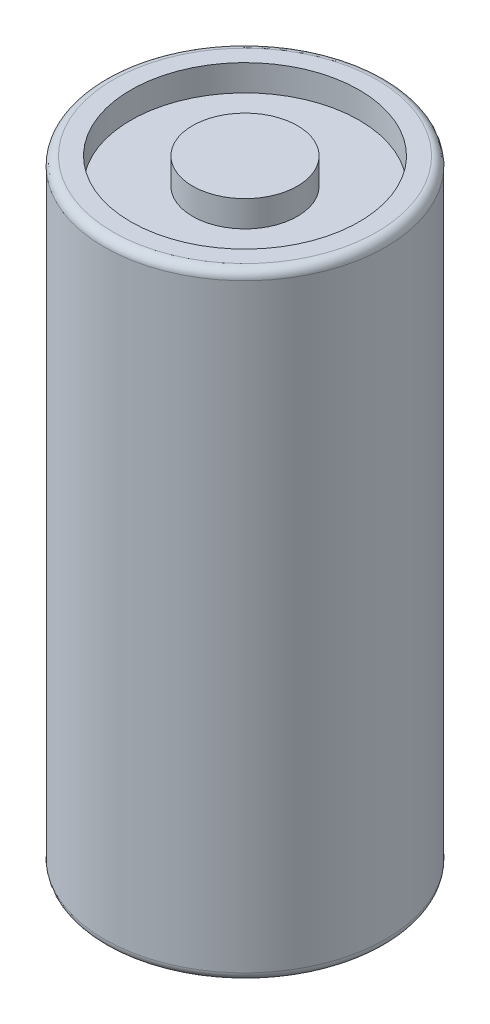
from build123d import *

# Parameters (mm, degrees)
SKETCH_1_R          = 16.1
EXTRUDE_1_DEPTH     = 70.6
SKETCH_3_R          = 13.073776485
SKETCH_3_R_2        = 6
CUT_EXTRUDE_1_DEPTH = 3
FILLET_1_R          = 1
FILLET_2_R          = 1


with BuildPart() as part:
    # 草图1 → 凸台-拉伸1 (new body)
    with BuildSketch(Plane(origin=(0, 0, 0), x_dir=(1, 0, 0), z_dir=(0, 1, 0))):
        Circle(SKETCH_1_R)
    extrude(amount=EXTRUDE_1_DEPTH)

    # 草图3 → 切除-拉伸1 (cut)
    with BuildSketch(Plane(origin=(0, 70.6, 0), x_dir=(1, 0, 0), z_dir=(0, 1, 0))):
        Circle(SKETCH_3_R)
        Circle(SKETCH_3_R_2, mode=Mode.SUBTRACT)
    extrude(amount=-CUT_EXTRUDE_1_DEPTH, mode=Mode.SUBTRACT)

    # 圆角1
    fillet_1_edges = [part.edges().sort_by_distance(p)[0] for p in [
        (-16.1, 0, 0),
    ]]
    fillet(fillet_1_edges, radius=FILLET_1_R)

    # 圆角2
    fillet_2_edges = [part.edges().sort_by_distance(p)[0] for p in [
        (-16.1, 70.6, 0),
    ]]
    fillet(fillet_2_edges, radius=FILLET_2_R)


solid = part.part
